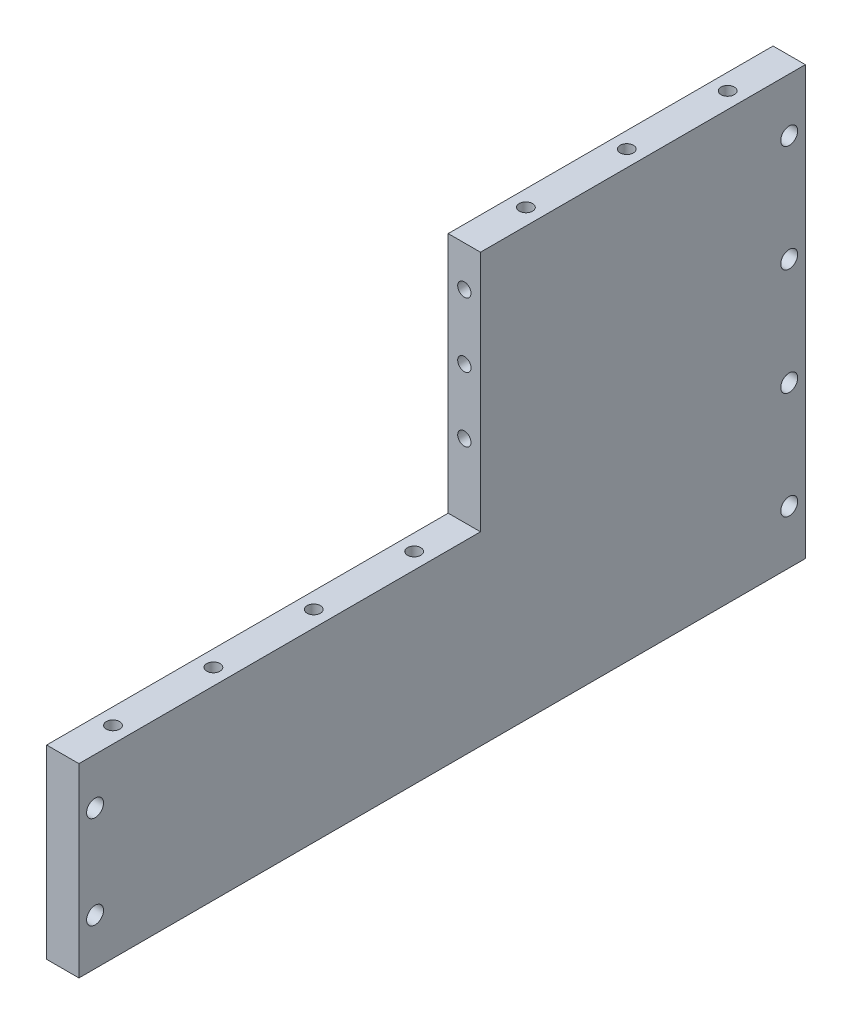
from build123d import *

# Parameters (mm, degrees)
SKETCH1_W           = 8
SKETCH1_H           = 46
SKETCH1_R           = 2.1
SKETCH1_H_2         = 106
BOSS_EXTRUDE1_DEPTH = 8
SKETCH2_R           = 1.65
CUT_EXTRUDE1_DEPTH  = 5
SKETCH3_R           = 1.65
CUT_EXTRUDE2_DEPTH  = 10
SKETCH4_R           = 1.65
CUT_EXTRUDE3_DEPTH  = 10
SKETCH5_R           = 1.65
CUT_EXTRUDE4_DEPTH  = 10


with BuildPart() as part:
    # Sketch1 → Boss-Extrude1 (new body)
    with BuildSketch(Plane(origin=(0, 0, 0), x_dir=(0, 0, -1), z_dir=(1, 0, 0))):
        with Locations((-86, -30)):
            Rectangle(SKETCH1_W, SKETCH1_H)
        with Locations((-86, -41.5)):
            Circle(SKETCH1_R, mode=Mode.SUBTRACT)
        with Locations((-86, -18.5)):
            Circle(SKETCH1_R, mode=Mode.SUBTRACT)
        Polygon((82, 53), (9.5, 53), (9.5, -7), (-82, -7), (-82, -53), (82, -53), align=None)
        with Locations((86, 0)):
            Rectangle(SKETCH1_W, SKETCH1_H_2)
        with Locations((86, -39.75)):
            Circle(SKETCH1_R, mode=Mode.SUBTRACT)
        with Locations((86, -13.25)):
            Circle(SKETCH1_R, mode=Mode.SUBTRACT)
        with Locations((86, 13.25)):
            Circle(SKETCH1_R, mode=Mode.SUBTRACT)
        with Locations((86, 39.75)):
            Circle(SKETCH1_R, mode=Mode.SUBTRACT)
    extrude(amount=-BOSS_EXTRUDE1_DEPTH)

    # Sketch2 → Cut-Extrude1 (cut)
    with BuildSketch(Plane.XZ.offset(53)):
        with Locations((-4, -86)):
            Circle(SKETCH2_R)
        with Locations((-4, -4.5)):
            Circle(SKETCH2_R)
        with Locations((-4, -45.25)):
            Circle(SKETCH2_R)
    extrude(amount=-CUT_EXTRUDE1_DEPTH, mode=Mode.SUBTRACT)

    # Sketch3 → Cut-Extrude2 (cut)
    with BuildSketch(Plane(origin=(0, 53, 0), x_dir=(1, 0, 0), z_dir=(0, 1, 0))):
        with Locations((-4, 49.75)):
            Circle(SKETCH3_R)
        with Locations((-4, 74.75)):
            Circle(SKETCH3_R)
        with Locations((-4, 24.75)):
            Circle(SKETCH3_R)
    extrude(amount=-CUT_EXTRUDE2_DEPTH, mode=Mode.SUBTRACT)

    # Sketch4 → Cut-Extrude3 (cut)
    with BuildSketch(Plane(origin=(0, -7, 0), x_dir=(1, 0, 0), z_dir=(0, 1, 0))):
        with Locations((-4, -2.9375)):
            Circle(SKETCH4_R)
        with Locations((-4, -27.8125)):
            Circle(SKETCH4_R)
        with Locations((-4, -52.6875)):
            Circle(SKETCH4_R)
        with Locations((-4, -77.5625)):
            Circle(SKETCH4_R)
    extrude(amount=-CUT_EXTRUDE3_DEPTH, mode=Mode.SUBTRACT)

    # Sketch5 → Cut-Extrude4 (cut)
    with BuildSketch(Plane.XY.offset(-9.5)):
        with Locations((-4, 11)):
            Circle(SKETCH5_R)
        with Locations((-4, 43)):
            Circle(SKETCH5_R)
        with Locations((-4, 27)):
            Circle(SKETCH5_R)
    extrude(amount=-CUT_EXTRUDE4_DEPTH, mode=Mode.SUBTRACT)


solid = part.part
